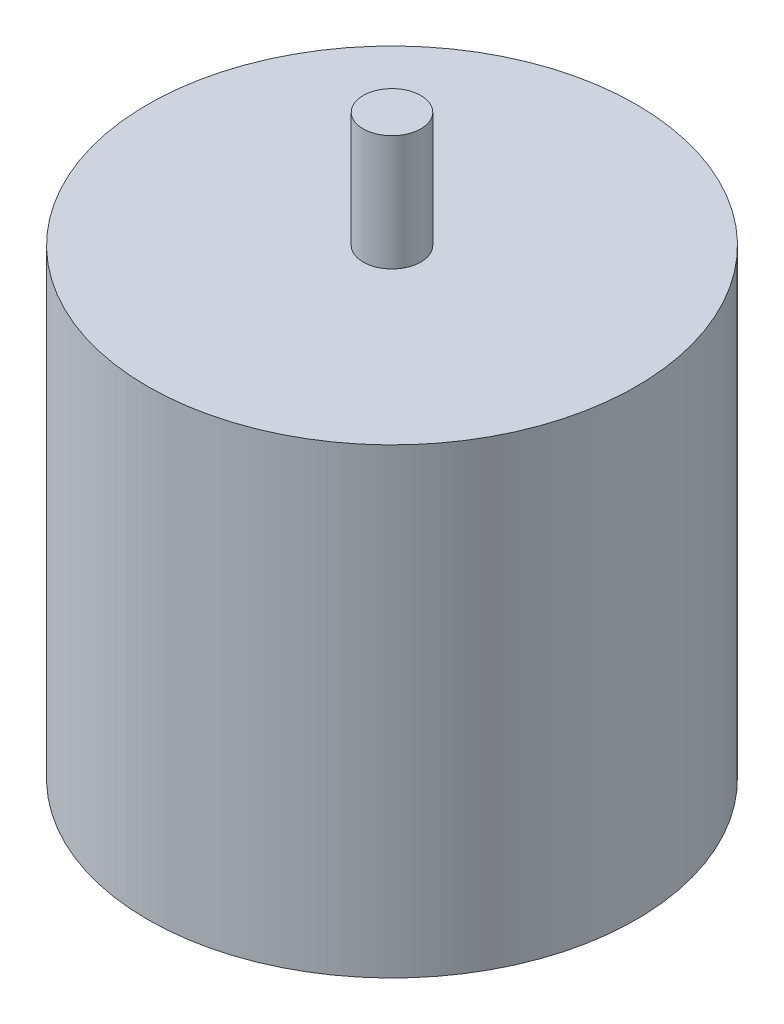
from build123d import *

# Parameters (mm, degrees)
SKETCH1_R                = 21.166666667
SKETCH1_R_2              = 2.5
BOSS_EXTRUDE1_DEPTH      = 40
SKETCH2_R                = 2.5
BOSS_EXTRUDE2_DEPTH      = 10
BOSS_EXTRUDE2_DEPTH_BACK = 30


with BuildPart() as part:
    # Sketch1 → Boss-Extrude1 (new body)
    with BuildSketch(Plane(origin=(0, 0, 0), x_dir=(1, 0, 0), z_dir=(0, 1, 0))):
        Circle(SKETCH1_R)
        Circle(SKETCH1_R_2, mode=Mode.SUBTRACT)
    extrude(amount=BOSS_EXTRUDE1_DEPTH)

    # Sketch2 → Boss-Extrude2 (add, two sides)
    with BuildSketch(Plane(origin=(0, 40, 0), x_dir=(1, 0, 0), z_dir=(0, 1, 0))) as boss_extrude2_sk:
        Circle(SKETCH2_R)
    extrude(amount=BOSS_EXTRUDE2_DEPTH)
    extrude(boss_extrude2_sk.sketch, amount=-BOSS_EXTRUDE2_DEPTH_BACK)


solid = part.part
